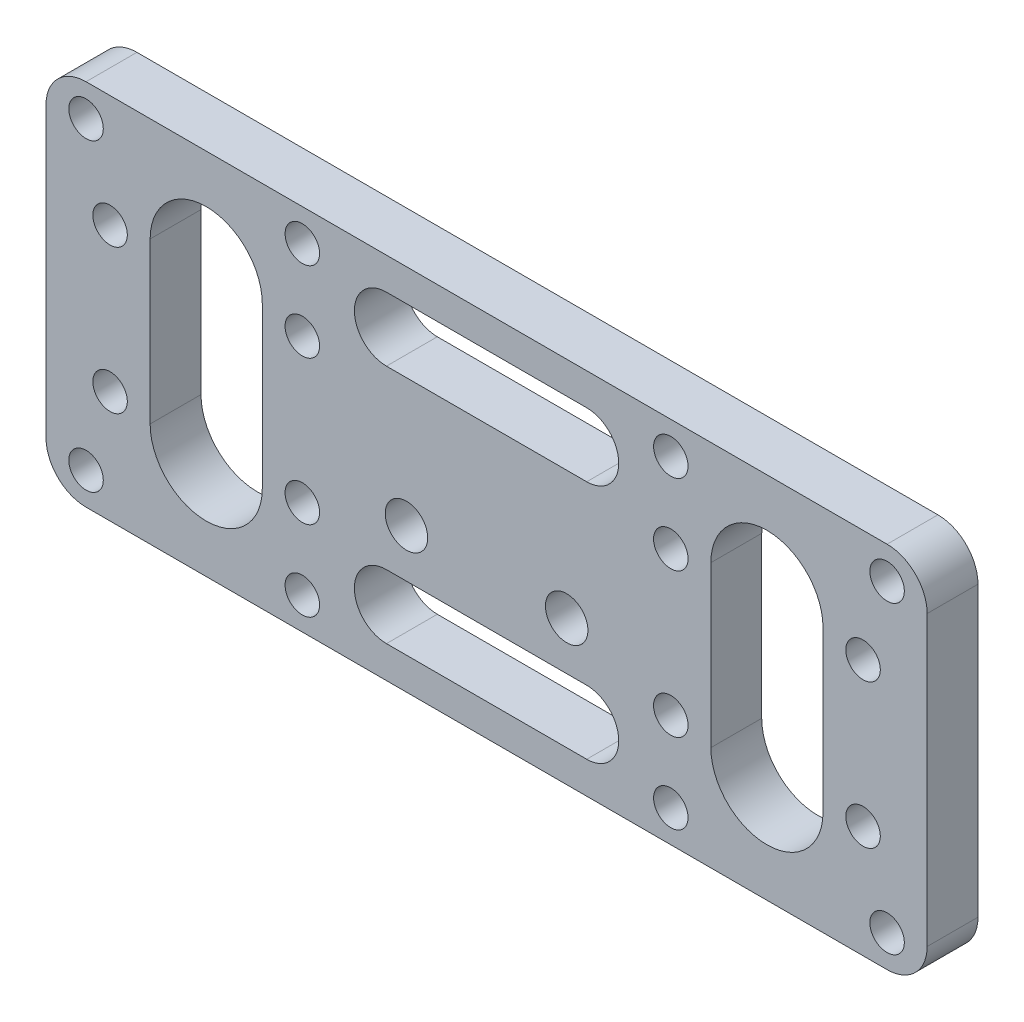
from build123d import *

# Parameters (mm, degrees)
SKETCH1_W             = 110
SKETCH1_H             = 46
BOSS_EXTRUDE1_DEPTH   = 6.35
F_8_CLEARANCE_HOLE2_D = 4.3053
FILLET1_R             = 5
M5_CLEARANCE_HOLE1_D  = 5.3
F_8_CLEARANCE_HOLE1_D = 4.3053
SKETCH13_R            = 2.15265
CUT_EXTRUDE2_DEPTH    = 10
CUT_EXTRUDE3_DEPTH    = 7.35


with BuildPart() as part:
    # Sketch1 → Boss-Extrude1 (new body)
    with BuildSketch(Plane.XY):
        Rectangle(SKETCH1_W, SKETCH1_H)
    extrude(amount=BOSS_EXTRUDE1_DEPTH)

    # #8 Clearance Hole2 (through all)
    with Locations(Plane(origin=(0, 0, 0), x_dir=(-1, 0, 0), z_dir=(0, 0, -1))):
        with Locations((-47, 9), (-23, 9), (-23, -9), (-47, -9), (23, -9), (23, 9), (47, 9), (47, -9)):
            Hole(F_8_CLEARANCE_HOLE2_D / 2)

    # Fillet1
    fillet1_edges = [part.edges().sort_by_distance(p)[0] for p in [
        (-55, -23, 3.175),
        (-55, 23, 3.175),
        (55, 23, 3.175),
        (55, -23, 3.175),
    ]]
    fillet(fillet1_edges, radius=FILLET1_R)

    # M5 Clearance Hole1 (through all)
    with Locations(Plane.XY.offset(6.35)):
        with Locations((-10, -5), (10, -5)):
            Hole(M5_CLEARANCE_HOLE1_D / 2)

    # #8 Clearance Hole1 (through all)
    with Locations(Plane.XY.offset(6.35)):
        with Locations((-23, 19), (-23, -19), (23, -19), (23, 19), (-50, 19), (-50, -19), (50, -19), (50, 19)):
            Hole(F_8_CLEARANCE_HOLE1_D / 2)

    # Sketch13 → Cut-Extrude2 (cut)
    with BuildSketch(Plane.XY.offset(6.35)):
        with Locations((47, 9)):
            Circle(SKETCH13_R)
        with Locations((23, -9)):
            Circle(SKETCH13_R)
        with Locations((23, 9)):
            Circle(SKETCH13_R)
        with Locations((47, -9)):
            Circle(SKETCH13_R)
        with BuildLine():
            Line((42, 10), (42, -10))
            ThreePointArc((42, -10), (35, -17), (28, -10))
            Line((28, -10), (28, 10))
            ThreePointArc((28, 10), (35, 17), (42, 10))
        make_face()
        with BuildLine():
            Line((-42, 10), (-42, -10))
            ThreePointArc((-42, -10), (-35, -17), (-28, -10))
            Line((-28, -10), (-28, 10))
            ThreePointArc((-28, 10), (-35, 17), (-42, 10))
        make_face()
    extrude(amount=-CUT_EXTRUDE2_DEPTH, mode=Mode.SUBTRACT)

    # Sketch14 → Cut-Extrude3 (cut, through all)
    with BuildSketch(Plane.XY.offset(6.35)):
        with BuildLine():
            Line((-12.5, -11), (12.5, -11))
            ThreePointArc((12.5, -11), (16.5, -15), (12.5, -19))
            Line((12.5, -19), (-12.5, -19))
            ThreePointArc((-12.5, -19), (-16.5, -15), (-12.5, -11))
        make_face()
        with BuildLine():
            Line((-12.5, 19), (12.5, 19))
            ThreePointArc((12.5, 19), (16.5, 15), (12.5, 11))
            Line((12.5, 11), (-12.5, 11))
            ThreePointArc((-12.5, 11), (-16.5, 15), (-12.5, 19))
        make_face()
    extrude(amount=-CUT_EXTRUDE3_DEPTH, mode=Mode.SUBTRACT)


solid = part.part
